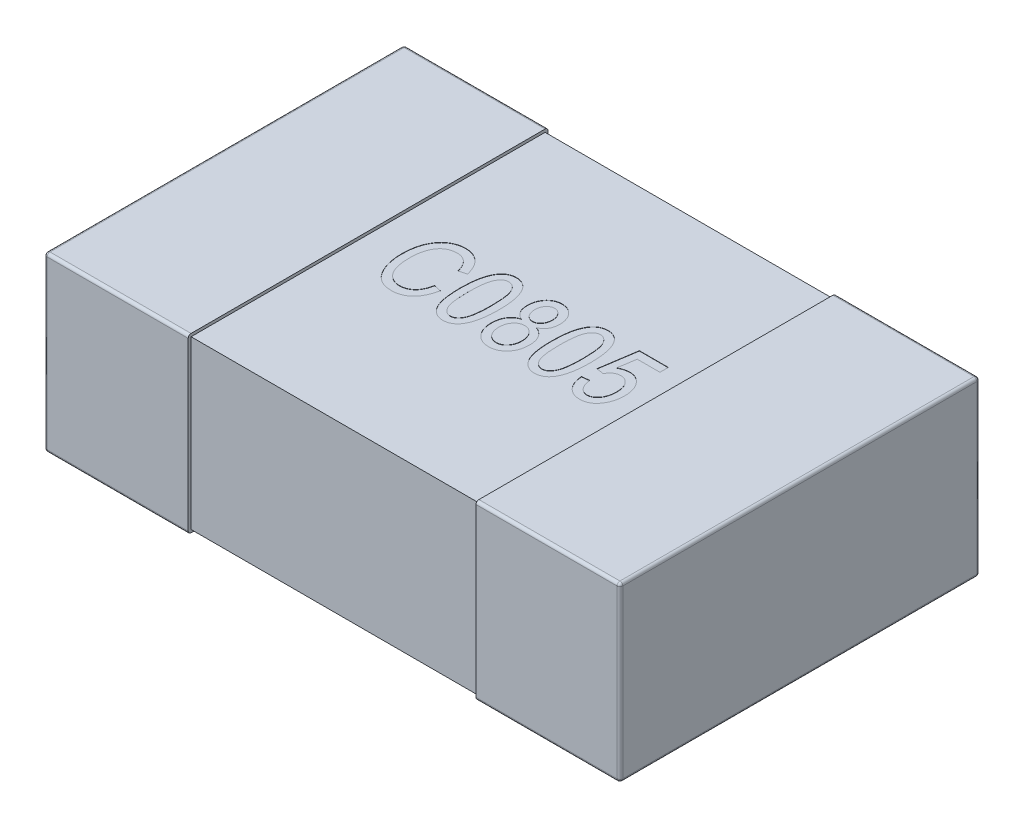
from build123d import *

# Parameters (mm, degrees)
SKETCH1_W            = 0.5
SKETCH1_H            = 1.25
THICKNESS_DEPTH      = 0.6
FILLET1_R            = 0.01
SKETCH2_W            = 1.23
SKETCH2_H            = 0.58
BOSS_EXTRUDE2_DEPTH  = 0.5
FILLET1_OF_MIRROR3_R = 0.01
CUT_EXTRUDE1_DEPTH   = 0.001


with BuildPart() as part:
    # Sketch1 → THICKNESS (new body)
    with BuildSketch(Plane(origin=(0, 0, 0), x_dir=(1, 0, 0), z_dir=(0, 1, 0))):
        with Locations((-0.75, 0)):
            Rectangle(SKETCH1_W, SKETCH1_H)
    thickness = extrude(amount=THICKNESS_DEPTH)

    # Fillet1
    fillet1_edges = [part.edges().sort_by_distance(p)[0] for p in [
        (-0.75, 0.6, -0.625),
        (-1, 0.6, 0),
        (-0.75, 0, -0.625),
        (-0.75, 0, 0.625),
        (-1, 0, 0),
        (-0.75, 0.6, 0.625),
        (-1, 0.3, -0.625),
        (-1, 0.3, 0.625),
    ]]
    fillet(fillet1_edges, radius=FILLET1_R)

    # Sketch2 → Boss-Extrude2 (add)
    with BuildSketch(Plane(origin=(0, 0, 0), x_dir=(0, 0, -1), z_dir=(1, 0, 0))):
        with Locations((0, 0.3)):
            Rectangle(SKETCH2_W, SKETCH2_H)
    boss_extrude2 = extrude(amount=-BOSS_EXTRUDE2_DEPTH)

    # Mirror3: THICKNESS, Boss-Extrude2 across plane
    add(thickness.mirror(Plane(origin=(0, 0, 0), x_dir=(0, 0, 1), z_dir=(1, 0, 0))))
    add(boss_extrude2.mirror(Plane(origin=(0, 0, 0), x_dir=(0, 0, 1), z_dir=(1, 0, 0))))

    # Fillet1 of Mirror3
    fillet1_of_mirror3_edges = [part.edges().sort_by_distance(p)[0] for p in [
        (0.75, 0.6, -0.625),
        (1, 0.6, 0),
        (0.75, 0, -0.625),
        (0.75, 0, 0.625),
        (1, 0, 0),
        (0.75, 0.6, 0.625),
        (1, 0.3, -0.625),
        (1, 0.3, 0.625),
    ]]
    fillet(fillet1_of_mirror3_edges, radius=FILLET1_OF_MIRROR3_R)

    # Sketch3 → Cut-Extrude1 (cut)
    with BuildSketch(Plane(origin=(0, 0.59, 0), x_dir=(1, 0, 0), z_dir=(0, 1, 0))):
        with BuildLine():
            Line((-0.231168831, -0.037337662), (-0.205194805, -0.043831169))
            add(Edge.make_bspline(
                [(-0.205194805, -0.043831169), (-0.205968965, -0.047273204), (-0.207478255, -0.053983737), (-0.210309184, -0.063635675), (-0.213617187, -0.072593423), (-0.217311677, -0.080890917), (-0.22142228, -0.088529429), (-0.22592876, -0.095503706), (-0.230869053, -0.101808046), (-0.236267766, -0.107364816), (-0.241944682, -0.112350711), (-0.248032026, -0.116535886), (-0.254346658, -0.120203809), (-0.26100923, -0.12312515), (-0.267952491, -0.12543899), (-0.275213822, -0.127035185), (-0.28276372, -0.128104831), (-0.287915608, -0.128199056), (-0.290523539, -0.128246753)],
                knots=[0, 0, 0, 0, 1.0582e-05, 2.0631e-05, 3.0149e-05, 3.921e-05, 4.7858e-05, 5.6146e-05, 6.4092e-05, 7.1842e-05, 7.9358e-05, 8.6719e-05, 9.3968e-05, 0.000101235, 0.000108503, 0.000115887, 0.000123514, 0.000131332, 0.000131332, 0.000131332, 0.000131332], degree=3))
            add(Edge.make_bspline(
                [(-0.290523539, -0.128246753), (-0.292825256, -0.128214993), (-0.297337162, -0.128152735), (-0.303977054, -0.127448949), (-0.310377642, -0.126420938), (-0.316524107, -0.124873245), (-0.322429991, -0.122978556), (-0.32803827, -0.120545225), (-0.333440076, -0.117775927), (-0.33857358, -0.114503183), (-0.343499773, -0.110795587), (-0.348086449, -0.106484738), (-0.352555473, -0.101772489), (-0.356677828, -0.096433674), (-0.360733341, -0.090681143), (-0.364379303, -0.084299811), (-0.367916321, -0.077476372), (-0.371173624, -0.07015596), (-0.374207584, -0.062412188), (-0.376685204, -0.054233559), (-0.37889496, -0.045762414), (-0.380648734, -0.036933097), (-0.382095747, -0.02778229), (-0.38301208, -0.018260327), (-0.383659727, -0.008413308), (-0.383730335, -0.001725961), (-0.383766234, 0.001674107)],
                knots=[0, 0, 0, 0, 6.902e-06, 1.353e-05, 2.001e-05, 2.6335e-05, 3.2527e-05, 3.8596e-05, 4.4654e-05, 5.072e-05, 5.6838e-05, 6.312e-05, 6.9581e-05, 7.63e-05, 8.3336e-05, 9.0679e-05, 9.8325e-05, 0.000106387, 0.000114706, 0.000123258, 0.000132006, 0.000140961, 0.000150252, 0.000159787, 0.000169648, 0.000179847, 0.000179847, 0.000179847, 0.000179847], degree=3))
            add(Edge.make_bspline(
                [(-0.383766234, 0.001674107), (-0.383730628, 0.005023478), (-0.383660793, 0.011592639), (-0.383014207, 0.021236978), (-0.382100205, 0.030506464), (-0.380648094, 0.039369282), (-0.378906317, 0.047863998), (-0.376704809, 0.055934078), (-0.374190115, 0.063645915), (-0.371199841, 0.070925759), (-0.367830189, 0.07777941), (-0.364229433, 0.084235387), (-0.360389227, 0.090294277), (-0.356221673, 0.09589401), (-0.351749021, 0.101020684), (-0.347007571, 0.105725638), (-0.341972704, 0.10997961), (-0.336702676, 0.113859575), (-0.331180168, 0.117222312), (-0.325519076, 0.12020861), (-0.319676812, 0.122686433), (-0.313674698, 0.124722564), (-0.307518536, 0.126305307), (-0.301206006, 0.12739352), (-0.294753004, 0.128161063), (-0.290390553, 0.128218021), (-0.288189935, 0.128246753)],
                knots=[0, 0, 0, 0, 1.0047e-05, 1.9705e-05, 2.8988e-05, 3.7979e-05, 4.6635e-05, 5.4991e-05, 6.306e-05, 7.0954e-05, 7.8578e-05, 8.5959e-05, 9.3122e-05, 0.000100082, 0.000106878, 0.000113515, 0.000120101, 0.000126636, 0.000133126, 0.00013948, 0.000145821, 0.000152142, 0.000158479, 0.000164868, 0.000171349, 0.000177948, 0.000177948, 0.000177948, 0.000177948], degree=3))
            add(Edge.make_bspline(
                [(-0.288189935, 0.128246753), (-0.285786544, 0.12818453), (-0.281065468, 0.128062302), (-0.27409222, 0.12720637), (-0.267421527, 0.125649629), (-0.260941178, 0.123644025), (-0.254772783, 0.120932796), (-0.248836643, 0.117670986), (-0.243184534, 0.113789845), (-0.237812765, 0.10931328), (-0.232727167, 0.104296702), (-0.228042938, 0.098687559), (-0.223802839, 0.092510719), (-0.219842083, 0.085852669), (-0.216430726, 0.078551126), (-0.213354929, 0.070734496), (-0.21055449, 0.062389431), (-0.209157696, 0.05656012), (-0.208441558, 0.053571429)],
                knots=[0, 0, 0, 0, 7.21e-06, 1.4163e-05, 2.103e-05, 2.7737e-05, 3.4485e-05, 4.1206e-05, 4.803e-05, 5.5019e-05, 6.2158e-05, 6.9433e-05, 7.6905e-05, 8.4614e-05, 9.2647e-05, 0.00010105, 0.000109809, 0.000119025, 0.000119025, 0.000119025, 0.000119025], degree=3))
            Line((-0.208441558, 0.053571429), (-0.234415584, 0.047077922))
            add(Edge.make_bspline(
                [(-0.234415584, 0.047077922), (-0.23500265, 0.049181367), (-0.236147605, 0.053283718), (-0.238185085, 0.059175943), (-0.240413527, 0.064665864), (-0.242835415, 0.069768302), (-0.245532383, 0.074438981), (-0.248425607, 0.078715963), (-0.251520038, 0.082611153), (-0.254880673, 0.08604242), (-0.258395665, 0.089138381), (-0.262172725, 0.091790554), (-0.266180492, 0.094006199), (-0.27038275, 0.095868718), (-0.274792779, 0.097269665), (-0.279425079, 0.098301565), (-0.284267339, 0.098910232), (-0.287579473, 0.098987088), (-0.289255276, 0.099025974)],
                knots=[0, 0, 0, 0, 6.55e-06, 1.2775e-05, 1.8691e-05, 2.4318e-05, 2.9705e-05, 3.4855e-05, 3.9798e-05, 4.4606e-05, 4.9244e-05, 5.3833e-05, 5.842e-05, 6.2963e-05, 6.76e-05, 7.2277e-05, 7.7185e-05, 8.2211e-05, 8.2211e-05, 8.2211e-05, 8.2211e-05], degree=3))
            add(Edge.make_bspline(
                [(-0.289255276, 0.099025974), (-0.292562979, 0.098903427), (-0.299017461, 0.098664295), (-0.308352597, 0.096675161), (-0.317038414, 0.093493465), (-0.323649229, 0.089675624), (-0.328550756, 0.086013742), (-0.332025044, 0.082883115), (-0.33529639, 0.079388167), (-0.338404619, 0.075562178), (-0.341348899, 0.071373856), (-0.344004018, 0.066772211), (-0.346579011, 0.061887791), (-0.348899355, 0.056616335), (-0.35096647, 0.050986827), (-0.352805045, 0.045011451), (-0.35437315, 0.038679632), (-0.355638058, 0.031972096), (-0.356578558, 0.02490781), (-0.357303678, 0.017480962), (-0.357693038, 0.009693713), (-0.357758745, 0.004380116), (-0.357792208, 0.001674107)],
                knots=[0, 0, 0, 0, 9.914e-06, 1.9346e-05, 2.8496e-05, 3.7564e-05, 4.2129e-05, 4.6835e-05, 5.1572e-05, 5.6477e-05, 6.1614e-05, 6.6912e-05, 7.2403e-05, 7.8172e-05, 8.4175e-05, 9.0385e-05, 9.6919e-05, 0.000103734, 0.000110851, 0.000118292, 0.000126115, 0.000134233, 0.000134233, 0.000134233, 0.000134233], degree=3))
            add(Edge.make_bspline(
                [(-0.357792208, 0.001674107), (-0.357728045, -0.002385607), (-0.357603596, -0.010259723), (-0.356810064, -0.021695507), (-0.355421735, -0.032360536), (-0.353383666, -0.042219257), (-0.350866218, -0.051303395), (-0.347803354, -0.059616425), (-0.344078971, -0.067123445), (-0.339824042, -0.073840071), (-0.335076544, -0.079761457), (-0.32995428, -0.084920573), (-0.324424924, -0.089264712), (-0.318555631, -0.09287674), (-0.312259011, -0.095608828), (-0.305623473, -0.097607303), (-0.298598123, -0.098792817), (-0.293791734, -0.098947114), (-0.291335227, -0.099025974)],
                knots=[0, 0, 0, 0, 1.2179e-05, 2.3622e-05, 3.437e-05, 4.4419e-05, 5.3798e-05, 6.2627e-05, 7.0954e-05, 7.8891e-05, 8.6434e-05, 9.368e-05, 0.000100652, 0.000107482, 0.000114296, 0.000121182, 0.000128229, 0.000135596, 0.000135596, 0.000135596, 0.000135596], degree=3))
            add(Edge.make_bspline(
                [(-0.291335227, -0.099025974), (-0.289506447, -0.098975677), (-0.285902636, -0.098876561), (-0.280589632, -0.098136185), (-0.27545054, -0.096991349), (-0.270498383, -0.095311137), (-0.265786495, -0.093096502), (-0.261219796, -0.090518091), (-0.256892634, -0.087376125), (-0.252744503, -0.083801559), (-0.248860727, -0.079713192), (-0.245310264, -0.075115309), (-0.242039551, -0.07004538), (-0.239233703, -0.064419613), (-0.23668226, -0.058355899), (-0.234454991, -0.051798345), (-0.232574721, -0.044746988), (-0.231644997, -0.039847153), (-0.231168831, -0.037337662)],
                knots=[0, 0, 0, 0, 5.485e-06, 1.0808e-05, 1.6063e-05, 2.1261e-05, 2.6459e-05, 3.1663e-05, 3.697e-05, 4.2473e-05, 4.8071e-05, 5.3855e-05, 5.9878e-05, 6.614e-05, 7.2688e-05, 7.9602e-05, 8.69e-05, 9.456e-05, 9.456e-05, 9.456e-05, 9.456e-05], degree=3))
        make_face()
        with BuildLine():
            add(Edge.make_bspline(
                [(-0.179220779, -0.000101461), (-0.179179533, 0.005006574), (-0.179099444, 0.014925148), (-0.178271735, 0.029310918), (-0.176966194, 0.042750423), (-0.175190833, 0.055225643), (-0.172788092, 0.066738449), (-0.169958625, 0.077307314), (-0.166483475, 0.086898626), (-0.162571978, 0.095553513), (-0.158086391, 0.103223649), (-0.153141222, 0.10993539), (-0.147589777, 0.115579805), (-0.141585133, 0.120273356), (-0.135007833, 0.12384902), (-0.127951495, 0.126418777), (-0.120390032, 0.127969473), (-0.115172358, 0.128153074), (-0.112510146, 0.128246753)],
                knots=[0, 0, 0, 0, 1.5323e-05, 2.9753e-05, 4.3211e-05, 5.5823e-05, 6.7534e-05, 7.8475e-05, 8.8617e-05, 9.8105e-05, 0.000106928, 0.000115227, 0.000123048, 0.000130607, 0.000138008, 0.000145407, 0.000153068, 0.000161049, 0.000161049, 0.000161049, 0.000161049], degree=3))
            add(Edge.make_bspline(
                [(-0.112510146, 0.128246753), (-0.11013769, 0.128170646), (-0.105478729, 0.12802119), (-0.098680126, 0.126788688), (-0.092285601, 0.124691913), (-0.086290323, 0.121778021), (-0.080712505, 0.118015925), (-0.075497266, 0.11346708), (-0.070701759, 0.108039774), (-0.067924896, 0.10396259), (-0.066497565, 0.101866883)],
                knots=[0, 0, 0, 0, 7.114e-06, 1.397e-05, 2.0644e-05, 2.7246e-05, 3.3901e-05, 4.0769e-05, 4.7956e-05, 5.5558e-05, 5.5558e-05, 5.5558e-05, 5.5558e-05], degree=3))
            add(Edge.make_bspline(
                [(-0.066497565, 0.101866883), (-0.064845388, 0.099041395), (-0.061409512, 0.093165494), (-0.05730691, 0.083320552), (-0.053848794, 0.072324578), (-0.050933052, 0.060142576), (-0.048853186, 0.046749428), (-0.0472071, 0.032197231), (-0.046254426, 0.016449408), (-0.046155276, 0.00554781), (-0.046103896, -0.000101461)],
                knots=[0, 0, 0, 0, 9.81e-06, 2.0402e-05, 3.1905e-05, 4.437e-05, 5.7939e-05, 7.2539e-05, 8.8295e-05, 0.000105241, 0.000105241, 0.000105241, 0.000105241], degree=3))
            add(Edge.make_bspline(
                [(-0.046103896, -0.000101461), (-0.046144642, -0.00517574), (-0.046223745, -0.01502685), (-0.047059737, -0.029344109), (-0.048347884, -0.042718306), (-0.050147358, -0.055155476), (-0.052527816, -0.066640018), (-0.055394879, -0.077206009), (-0.058761574, -0.086848769), (-0.062727214, -0.095504579), (-0.067146769, -0.103219465), (-0.072175828, -0.109863192), (-0.077593483, -0.115608492), (-0.083676071, -0.120200381), (-0.090208492, -0.123877255), (-0.097312386, -0.1264037), (-0.104899054, -0.127976131), (-0.110134815, -0.128155136), (-0.112814529, -0.128246753)],
                knots=[0, 0, 0, 0, 1.5221e-05, 2.955e-05, 4.3008e-05, 5.552e-05, 6.7231e-05, 7.8172e-05, 8.8344e-05, 9.7833e-05, 0.000106699, 0.000114958, 0.000122779, 0.000130308, 0.000137734, 0.00014518, 0.000152841, 0.000160872, 0.000160872, 0.000160872, 0.000160872], degree=3))
            add(Edge.make_bspline(
                [(-0.112814529, -0.128246753), (-0.115204627, -0.128157044), (-0.119903828, -0.127980665), (-0.126798792, -0.126639628), (-0.1333245, -0.124327432), (-0.139515421, -0.121150834), (-0.145379788, -0.117089582), (-0.150845947, -0.112058129), (-0.156045963, -0.10618892), (-0.160917296, -0.099373751), (-0.165319285, -0.091437437), (-0.16904038, -0.082191081), (-0.172210639, -0.071678848), (-0.174726393, -0.059858298), (-0.176843902, -0.046777746), (-0.178174674, -0.032371584), (-0.179056727, -0.016667611), (-0.179164667, -0.005767747), (-0.179220779, -0.000101461)],
                knots=[0, 0, 0, 0, 7.168e-06, 1.4092e-05, 2.0975e-05, 2.7873e-05, 3.4909e-05, 4.2307e-05, 5.0105e-05, 5.8397e-05, 6.7389e-05, 7.7262e-05, 8.8239e-05, 0.00010029, 0.000113492, 0.00012797, 0.000143669, 0.000160667, 0.000160667, 0.000160667, 0.000160667], degree=3))
        make_face()
        with BuildLine():
            add(Edge.make_bspline(
                [(-0.153246753, 0), (-0.153201463, -0.004870478), (-0.153114944, -0.014174538), (-0.152639473, -0.027525997), (-0.151740786, -0.039609099), (-0.150492603, -0.050461919), (-0.148910111, -0.060039625), (-0.146956953, -0.068394949), (-0.144629573, -0.075493918), (-0.141891409, -0.081437608), (-0.138854976, -0.086371634), (-0.135611674, -0.090576008), (-0.1322582, -0.09422232), (-0.128592398, -0.097134983), (-0.124786606, -0.099490077), (-0.120693762, -0.101026781), (-0.116458236, -0.102135963), (-0.113532141, -0.102226818), (-0.112053571, -0.102272727)],
                knots=[0, 0, 0, 0, 1.4612e-05, 2.7913e-05, 4.0072e-05, 5.0952e-05, 6.0676e-05, 6.9179e-05, 7.667e-05, 8.3048e-05, 8.8764e-05, 9.401e-05, 9.8963e-05, 0.000103582, 0.000108019, 0.000112324, 0.000116655, 0.000121079, 0.000121079, 0.000121079, 0.000121079], degree=3))
            add(Edge.make_bspline(
                [(-0.112053571, -0.102272727), (-0.110659797, -0.102224591), (-0.107884569, -0.102128745), (-0.103839162, -0.101030887), (-0.099939203, -0.099420452), (-0.096250237, -0.097089742), (-0.09277756, -0.094091995), (-0.089474108, -0.090452458), (-0.086334961, -0.086167132), (-0.083324707, -0.081159117), (-0.080615636, -0.075185232), (-0.078311364, -0.068052529), (-0.076372444, -0.059699885), (-0.074768611, -0.050127164), (-0.073606683, -0.039317254), (-0.072676443, -0.027307128), (-0.072213316, -0.014055917), (-0.072124348, -0.00481966), (-0.072077922, 0)],
                knots=[0, 0, 0, 0, 4.171e-06, 8.305e-06, 1.2489e-05, 1.6796e-05, 2.133e-05, 2.6213e-05, 3.151e-05, 3.7243e-05, 4.3713e-05, 5.1141e-05, 5.9692e-05, 6.9417e-05, 8.0241e-05, 9.2298e-05, 0.000105549, 0.000120008, 0.000120008, 0.000120008, 0.000120008], degree=3))
            add(Edge.make_bspline(
                [(-0.072077922, 0), (-0.072124141, 0.00487042), (-0.072212754, 0.014208164), (-0.072677993, 0.027577286), (-0.073592986, 0.039692504), (-0.074819086, 0.050531851), (-0.076431911, 0.060120015), (-0.078346386, 0.068469507), (-0.080711821, 0.075554192), (-0.083411098, 0.081486026), (-0.086509334, 0.086376159), (-0.089672696, 0.090644348), (-0.093139282, 0.094200445), (-0.096783038, 0.09716158), (-0.100657033, 0.099469005), (-0.104778265, 0.101117847), (-0.109114692, 0.102110041), (-0.112082311, 0.102218271), (-0.113575487, 0.102272727)],
                knots=[0, 0, 0, 0, 1.4612e-05, 2.8014e-05, 4.0123e-05, 5.1053e-05, 6.0727e-05, 6.9279e-05, 7.6723e-05, 8.3101e-05, 8.8774e-05, 9.406e-05, 9.9011e-05, 0.00010363, 0.00010811, 0.000112482, 0.0001169, 0.000121375, 0.000121375, 0.000121375, 0.000121375], degree=3))
            add(Edge.make_bspline(
                [(-0.113575487, 0.102272727), (-0.114969489, 0.102225863), (-0.117728739, 0.102133101), (-0.121740511, 0.101030616), (-0.125589213, 0.099418598), (-0.129251156, 0.09707752), (-0.132680131, 0.094037526), (-0.136010373, 0.090420532), (-0.139080674, 0.086096557), (-0.142101966, 0.081134389), (-0.14476353, 0.075144526), (-0.147071377, 0.068024231), (-0.148927552, 0.059656603), (-0.150567782, 0.050112686), (-0.151714861, 0.039316591), (-0.152649199, 0.027307333), (-0.153111081, 0.014055859), (-0.153200232, 0.00481964), (-0.153246753, 0)],
                knots=[0, 0, 0, 0, 4.171e-06, 8.256e-06, 1.2393e-05, 1.6657e-05, 2.1224e-05, 2.6108e-05, 3.1374e-05, 3.7107e-05, 4.351e-05, 5.0986e-05, 5.9526e-05, 6.9201e-05, 8.0024e-05, 9.2082e-05, 0.000105332, 0.000119792, 0.000119792, 0.000119792, 0.000119792], degree=3))
        make_face(mode=Mode.SUBTRACT)
        with BuildLine():
            add(Edge.make_bspline(
                [(0.019997971, 0.012175325), (0.017608115, 0.0133763), (0.012945467, 0.015719422), (0.006730686, 0.02030892), (0.001431301, 0.02563882), (-0.002934005, 0.031747513), (-0.006311444, 0.038640955), (-0.008659668, 0.046294944), (-0.010186541, 0.054694639), (-0.010320164, 0.060565062), (-0.01038961, 0.063616071)],
                knots=[0, 0, 0, 0, 8.013e-06, 1.5633e-05, 2.3058e-05, 3.0477e-05, 3.8055e-05, 4.5981e-05, 5.443e-05, 6.3572e-05, 6.3572e-05, 6.3572e-05, 6.3572e-05], degree=3))
            add(Edge.make_bspline(
                [(-0.01038961, 0.063616071), (-0.010343103, 0.065951742), (-0.010252187, 0.070517631), (-0.009476242, 0.077204767), (-0.008201828, 0.083544039), (-0.006514602, 0.089582043), (-0.004180434, 0.095226916), (-0.001458777, 0.10061212), (0.001863052, 0.105617845), (0.005597262, 0.110289613), (0.009741509, 0.114475142), (0.014170998, 0.118154266), (0.018871487, 0.121287748), (0.023853046, 0.123813893), (0.029069863, 0.12581356), (0.034542692, 0.127254407), (0.04028381, 0.128047994), (0.044194159, 0.128179925), (0.046174919, 0.128246753)],
                knots=[0, 0, 0, 0, 7.005e-06, 1.3695e-05, 2.0161e-05, 2.6391e-05, 3.2467e-05, 3.8457e-05, 4.4465e-05, 5.0455e-05, 5.6374e-05, 6.2103e-05, 6.7703e-05, 7.3284e-05, 7.8824e-05, 8.4435e-05, 9.0225e-05, 9.6168e-05, 9.6168e-05, 9.6168e-05, 9.6168e-05], degree=3))
            add(Edge.make_bspline(
                [(0.046174919, 0.128246753), (0.048173364, 0.128185644), (0.052121341, 0.128064921), (0.057903749, 0.127188225), (0.063429828, 0.125762902), (0.068699633, 0.123781922), (0.073704751, 0.121173058), (0.078412963, 0.1179611), (0.08288259, 0.114205513), (0.087054016, 0.109930777), (0.090840174, 0.105185973), (0.094140446, 0.100073908), (0.09702712, 0.094687108), (0.099296313, 0.088906486), (0.101078339, 0.082793196), (0.102327483, 0.076339823), (0.103108743, 0.069570771), (0.103200164, 0.064954147), (0.103246753, 0.062601461)],
                knots=[0, 0, 0, 0, 5.994e-06, 1.1841e-05, 1.7501e-05, 2.3088e-05, 2.8693e-05, 3.4392e-05, 4.0153e-05, 4.618e-05, 5.228e-05, 5.8331e-05, 6.4413e-05, 7.0583e-05, 7.6924e-05, 8.3491e-05, 9.0281e-05, 9.7337e-05, 9.7337e-05, 9.7337e-05, 9.7337e-05], degree=3))
            add(Edge.make_bspline(
                [(0.103246753, 0.062601461), (0.103172617, 0.059669122), (0.103029811, 0.054020637), (0.101556925, 0.045908671), (0.099263984, 0.038471636), (0.095925511, 0.031751468), (0.09165802, 0.025713207), (0.08641722, 0.020415964), (0.080255733, 0.015741534), (0.075574525, 0.013387649), (0.073163555, 0.012175325)],
                knots=[0, 0, 0, 0, 8.788e-06, 1.6929e-05, 2.4646e-05, 3.2065e-05, 3.9342e-05, 4.6732e-05, 5.4341e-05, 6.2423e-05, 6.2423e-05, 6.2423e-05, 6.2423e-05], degree=3))
            add(Edge.make_bspline(
                [(0.073163555, 0.012175325), (0.074730856, 0.011541303), (0.077834464, 0.010285797), (0.082229601, 0.007982466), (0.086375933, 0.00545861), (0.090181987, 0.002585376), (0.093761575, -0.000514351), (0.097067658, -0.003914682), (0.100060041, -0.007626133), (0.102743529, -0.011613566), (0.105220068, -0.015818365), (0.107256823, -0.020346538), (0.109067857, -0.025076774), (0.110466335, -0.030075821), (0.111587213, -0.035311267), (0.112380412, -0.040785545), (0.11292046, -0.046509091), (0.112964473, -0.050407914), (0.112987013, -0.052404627)],
                knots=[0, 0, 0, 0, 5.069e-06, 1.0038e-05, 1.4867e-05, 1.9616e-05, 2.4326e-05, 2.9062e-05, 3.3823e-05, 3.8607e-05, 4.3471e-05, 4.8442e-05, 5.3483e-05, 5.8654e-05, 6.3997e-05, 6.9536e-05, 7.524e-05, 8.1228e-05, 8.1228e-05, 8.1228e-05, 8.1228e-05], degree=3))
            add(Edge.make_bspline(
                [(0.112987013, -0.052404627), (0.112924289, -0.055128971), (0.112801245, -0.06047322), (0.111962079, -0.068307174), (0.110406011, -0.075745841), (0.108359177, -0.082827048), (0.105643865, -0.089491503), (0.102393485, -0.095804559), (0.098464689, -0.101681027), (0.094011502, -0.107147985), (0.089143503, -0.11208587), (0.083913765, -0.116389256), (0.07842076, -0.120067116), (0.072613938, -0.123097907), (0.066477918, -0.125351504), (0.060103133, -0.127070716), (0.05342392, -0.128019792), (0.048883285, -0.128170387), (0.046580763, -0.128246753)],
                knots=[0, 0, 0, 0, 8.173e-06, 1.6033e-05, 2.3595e-05, 3.0947e-05, 3.8116e-05, 4.515e-05, 5.2213e-05, 5.928e-05, 6.6275e-05, 7.2979e-05, 7.9563e-05, 8.6075e-05, 9.2577e-05, 9.9136e-05, 0.000105851, 0.000112759, 0.000112759, 0.000112759, 0.000112759], degree=3))
            add(Edge.make_bspline(
                [(0.046580763, -0.128246753), (0.044244329, -0.128171234), (0.039652912, -0.128022829), (0.03290762, -0.127068643), (0.02649382, -0.125363058), (0.020335464, -0.123083058), (0.014493798, -0.120085393), (0.008992181, -0.116370481), (0.003713386, -0.112106017), (-0.001145795, -0.107141214), (-0.005635397, -0.101693384), (-0.009463549, -0.095719505), (-0.012816475, -0.089395075), (-0.015489055, -0.08261756), (-0.01757827, -0.075433101), (-0.019021856, -0.067821782), (-0.019966305, -0.059818075), (-0.02007467, -0.054335152), (-0.02012987, -0.051542208)],
                knots=[0, 0, 0, 0, 7.01e-06, 1.3775e-05, 2.0383e-05, 2.6885e-05, 3.3442e-05, 4.0026e-05, 4.6769e-05, 5.3764e-05, 6.0831e-05, 6.7909e-05, 7.5012e-05, 8.2275e-05, 8.9724e-05, 9.7425e-05, 0.000105492, 0.000113868, 0.000113868, 0.000113868, 0.000113868], degree=3))
            add(Edge.make_bspline(
                [(-0.02012987, -0.051542208), (-0.020105339, -0.049495029), (-0.020057209, -0.04547859), (-0.019540722, -0.039580678), (-0.018679815, -0.033957395), (-0.017517657, -0.028617709), (-0.016051589, -0.02355646), (-0.014221417, -0.018770161), (-0.012043174, -0.014258951), (-0.009538475, -0.01002366), (-0.006767647, -0.006078371), (-0.003716303, -0.002457397), (-0.000392604, 0.00080643), (0.003173052, 0.003755844), (0.006986329, 0.006425967), (0.011099416, 0.008682661), (0.015442133, 0.010640312), (0.018466467, 0.01165931), (0.019997971, 0.012175325)],
                knots=[0, 0, 0, 0, 6.14e-06, 1.2047e-05, 1.7744e-05, 2.3197e-05, 2.843e-05, 3.3536e-05, 3.8551e-05, 4.344e-05, 4.8282e-05, 5.2998e-05, 5.7626e-05, 6.2237e-05, 6.6867e-05, 7.1568e-05, 7.6291e-05, 8.1137e-05, 8.1137e-05, 8.1137e-05, 8.1137e-05], degree=3))
        make_face()
        with BuildLine():
            add(Edge.make_bspline(
                [(0.015584416, 0.064326299), (0.015681946, 0.061426273), (0.015868564, 0.055877292), (0.017543422, 0.047987942), (0.020396088, 0.041038149), (0.024300914, 0.035093735), (0.029077906, 0.030376067), (0.034405847, 0.026834075), (0.040339547, 0.024704984), (0.044484134, 0.024469682), (0.046580763, 0.024350649)],
                knots=[0, 0, 0, 0, 8.693e-06, 1.6633e-05, 2.4048e-05, 3.1111e-05, 3.7819e-05, 4.4052e-05, 5.0181e-05, 5.6456e-05, 5.6456e-05, 5.6456e-05, 5.6456e-05], degree=3))
            add(Edge.make_bspline(
                [(0.046580763, 0.024350649), (0.048645523, 0.024467069), (0.052728084, 0.024697261), (0.058534425, 0.026865702), (0.063852353, 0.030256885), (0.068520979, 0.034949179), (0.072428184, 0.040686016), (0.075291127, 0.047324407), (0.076983146, 0.054755983), (0.07717379, 0.059954406), (0.077272727, 0.062652192)],
                knots=[0, 0, 0, 0, 6.174e-06, 1.2207e-05, 1.8343e-05, 2.4979e-05, 3.1916e-05, 3.905e-05, 4.6545e-05, 5.463e-05, 5.463e-05, 5.463e-05, 5.463e-05], degree=3))
            add(Edge.make_bspline(
                [(0.077272727, 0.062652192), (0.077177636, 0.065435004), (0.07699413, 0.070805279), (0.075251187, 0.078454847), (0.072329537, 0.085316018), (0.068261855, 0.091197581), (0.063522513, 0.096087467), (0.058182877, 0.099640676), (0.052379995, 0.101873404), (0.048324957, 0.102138701), (0.04627638, 0.102272727)],
                knots=[0, 0, 0, 0, 8.338e-06, 1.6092e-05, 2.3386e-05, 3.0576e-05, 3.7428e-05, 4.3689e-05, 4.9692e-05, 5.5821e-05, 5.5821e-05, 5.5821e-05, 5.5821e-05], degree=3))
            add(Edge.make_bspline(
                [(0.04627638, 0.102272727), (0.044229121, 0.102155063), (0.04018065, 0.101922381), (0.034382091, 0.09975932), (0.029097082, 0.096239407), (0.024422055, 0.091481379), (0.020428846, 0.085787592), (0.017664797, 0.079208436), (0.015852196, 0.071999073), (0.01567571, 0.066942191), (0.015584416, 0.064326299)],
                knots=[0, 0, 0, 0, 6.123e-06, 1.2109e-05, 1.83e-05, 2.5044e-05, 3.2009e-05, 3.903e-05, 4.6339e-05, 5.4171e-05, 5.4171e-05, 5.4171e-05, 5.4171e-05], degree=3))
        make_face(mode=Mode.SUBTRACT)
        with BuildLine():
            add(Edge.make_bspline(
                [(0.005844156, -0.051440747), (0.005884873, -0.053302408), (0.005964642, -0.056949654), (0.006536311, -0.062272698), (0.007418802, -0.067322331), (0.008764466, -0.072065995), (0.010425021, -0.07656287), (0.012508632, -0.080774419), (0.01497034, -0.084704052), (0.017720554, -0.088355861), (0.020828136, -0.091554825), (0.024032628, -0.09444962), (0.027409817, -0.096881589), (0.030975754, -0.098843506), (0.034676238, -0.100351385), (0.038510119, -0.101491776), (0.042498061, -0.102170047), (0.045208453, -0.102238214), (0.046580763, -0.102272727)],
                knots=[0, 0, 0, 0, 5.584e-06, 1.094e-05, 1.6045e-05, 2.0943e-05, 2.5711e-05, 3.0408e-05, 3.5011e-05, 3.9607e-05, 4.4092e-05, 4.8368e-05, 5.255e-05, 5.6546e-05, 6.055e-05, 6.4515e-05, 6.8526e-05, 7.264e-05, 7.264e-05, 7.264e-05, 7.264e-05], degree=3))
            add(Edge.make_bspline(
                [(0.046580763, -0.102272727), (0.047970557, -0.102240886), (0.050698993, -0.102178375), (0.05470781, -0.101468861), (0.058558747, -0.100428268), (0.062245393, -0.098930978), (0.065779462, -0.097047362), (0.069125944, -0.094704168), (0.072298569, -0.091910878), (0.075326353, -0.088766293), (0.07802805, -0.085196408), (0.080525134, -0.081414617), (0.082450424, -0.077244206), (0.084181872, -0.072878993), (0.085396866, -0.068167492), (0.08641322, -0.063198116), (0.086867911, -0.057908681), (0.08696394, -0.054299014), (0.087012987, -0.052455357)],
                knots=[0, 0, 0, 0, 4.165e-06, 8.176e-06, 1.2176e-05, 1.6114e-05, 2.0086e-05, 2.4167e-05, 2.8338e-05, 3.2752e-05, 3.7237e-05, 4.1754e-05, 4.6315e-05, 5.0988e-05, 5.5824e-05, 6.0888e-05, 6.6189e-05, 7.1722e-05, 7.1722e-05, 7.1722e-05, 7.1722e-05], degree=3))
            add(Edge.make_bspline(
                [(0.087012987, -0.052455357), (0.086970568, -0.050594015), (0.086887463, -0.046947395), (0.086339333, -0.041616781), (0.085371197, -0.036580034), (0.084046831, -0.03182905), (0.0823784, -0.027334315), (0.080300836, -0.023110366), (0.077802857, -0.019191134), (0.074946932, -0.01560315), (0.071895341, -0.012323666), (0.068638379, -0.009457317), (0.065207638, -0.007062986), (0.061653584, -0.00505338), (0.057925977, -0.003547349), (0.054078022, -0.0023968), (0.050054026, -0.001727338), (0.04731033, -0.001658319), (0.045921266, -0.001623377)],
                knots=[0, 0, 0, 0, 5.584e-06, 1.094e-05, 1.6054e-05, 2.0953e-05, 2.5721e-05, 3.0417e-05, 3.5047e-05, 3.9634e-05, 4.4157e-05, 4.8471e-05, 5.2623e-05, 5.6688e-05, 6.0692e-05, 6.4657e-05, 6.8718e-05, 7.2883e-05, 7.2883e-05, 7.2883e-05, 7.2883e-05], degree=3))
            add(Edge.make_bspline(
                [(0.045921266, -0.001623377), (0.044549268, -0.001658738), (0.041839492, -0.001728579), (0.0378631, -0.0023919), (0.034081875, -0.003563755), (0.030386814, -0.004975803), (0.026934724, -0.007036482), (0.023558253, -0.009387964), (0.020422725, -0.012279373), (0.017432548, -0.015503662), (0.014714112, -0.019088214), (0.012309924, -0.022948093), (0.010330764, -0.027091854), (0.008720132, -0.031482149), (0.00737612, -0.036100026), (0.00647224, -0.040993795), (0.005981738, -0.046137767), (0.005890687, -0.049647266), (0.005844156, -0.051440747)],
                knots=[0, 0, 0, 0, 4.114e-06, 8.126e-06, 1.2042e-05, 1.598e-05, 1.9957e-05, 2.4067e-05, 2.8305e-05, 3.2721e-05, 3.7247e-05, 4.178e-05, 4.6341e-05, 5.0996e-05, 5.5797e-05, 6.0752e-05, 6.5901e-05, 7.1282e-05, 7.1282e-05, 7.1282e-05, 7.1282e-05], degree=3))
        make_face(mode=Mode.SUBTRACT)
        with BuildLine():
            add(Edge.make_bspline(
                [(0.138961039, -0.000101461), (0.139002285, 0.005006574), (0.139082374, 0.014925148), (0.139910083, 0.029310918), (0.141215625, 0.042750423), (0.142990985, 0.055225643), (0.145393726, 0.066738449), (0.148223193, 0.077307314), (0.151698344, 0.086898626), (0.15560984, 0.095553513), (0.160095427, 0.103223649), (0.165040597, 0.10993539), (0.170592041, 0.115579805), (0.176596686, 0.120273356), (0.183173985, 0.12384902), (0.190230324, 0.126418777), (0.197791786, 0.127969473), (0.20300946, 0.128153074), (0.205671672, 0.128246753)],
                knots=[0, 0, 0, 0, 1.5323e-05, 2.9753e-05, 4.3211e-05, 5.5823e-05, 6.7534e-05, 7.8475e-05, 8.8617e-05, 9.8105e-05, 0.000106928, 0.000115227, 0.000123048, 0.000130607, 0.000138008, 0.000145407, 0.000153068, 0.000161049, 0.000161049, 0.000161049, 0.000161049], degree=3))
            add(Edge.make_bspline(
                [(0.205671672, 0.128246753), (0.208044128, 0.128170646), (0.212703089, 0.12802119), (0.219501692, 0.126788688), (0.225896217, 0.124691913), (0.231891495, 0.121778021), (0.237469313, 0.118015925), (0.242684552, 0.11346708), (0.247480059, 0.108039774), (0.250256922, 0.10396259), (0.251684253, 0.101866883)],
                knots=[0, 0, 0, 0, 7.114e-06, 1.397e-05, 2.0644e-05, 2.7246e-05, 3.3901e-05, 4.0769e-05, 4.7956e-05, 5.5558e-05, 5.5558e-05, 5.5558e-05, 5.5558e-05], degree=3))
            add(Edge.make_bspline(
                [(0.251684253, 0.101866883), (0.25333643, 0.099041395), (0.256772306, 0.093165494), (0.260874909, 0.083320552), (0.264333024, 0.072324578), (0.267248767, 0.060142576), (0.269328632, 0.046749428), (0.270974719, 0.032197231), (0.271927393, 0.016449408), (0.272026542, 0.00554781), (0.272077922, -0.000101461)],
                knots=[0, 0, 0, 0, 9.81e-06, 2.0402e-05, 3.1905e-05, 4.437e-05, 5.7939e-05, 7.2539e-05, 8.8295e-05, 0.000105241, 0.000105241, 0.000105241, 0.000105241], degree=3))
            add(Edge.make_bspline(
                [(0.272077922, -0.000101461), (0.272037176, -0.00517574), (0.271958073, -0.01502685), (0.271122081, -0.029344109), (0.269833934, -0.042718306), (0.26803446, -0.055155476), (0.265654003, -0.066640018), (0.262786939, -0.077206009), (0.259420244, -0.086848769), (0.255454604, -0.095504579), (0.251035049, -0.103219465), (0.24600599, -0.109863192), (0.240588335, -0.115608492), (0.234505748, -0.120200381), (0.227973326, -0.123877255), (0.220869432, -0.1264037), (0.213282764, -0.127976131), (0.208047003, -0.128155136), (0.205367289, -0.128246753)],
                knots=[0, 0, 0, 0, 1.5221e-05, 2.955e-05, 4.3008e-05, 5.552e-05, 6.7231e-05, 7.8172e-05, 8.8344e-05, 9.7833e-05, 0.000106699, 0.000114958, 0.000122779, 0.000130308, 0.000137734, 0.00014518, 0.000152841, 0.000160872, 0.000160872, 0.000160872, 0.000160872], degree=3))
            add(Edge.make_bspline(
                [(0.205367289, -0.128246753), (0.202977191, -0.128157044), (0.19827799, -0.127980665), (0.191383026, -0.126639628), (0.184857319, -0.124327432), (0.178666397, -0.121150834), (0.17280203, -0.117089582), (0.167335871, -0.112058129), (0.162135855, -0.10618892), (0.157264523, -0.099373751), (0.152862533, -0.091437437), (0.149141438, -0.082191081), (0.145971179, -0.071678848), (0.143455425, -0.059858298), (0.141337917, -0.046777746), (0.140007144, -0.032371584), (0.139125092, -0.016667611), (0.139017152, -0.005767747), (0.138961039, -0.000101461)],
                knots=[0, 0, 0, 0, 7.168e-06, 1.4092e-05, 2.0975e-05, 2.7873e-05, 3.4909e-05, 4.2307e-05, 5.0105e-05, 5.8397e-05, 6.7389e-05, 7.7262e-05, 8.8239e-05, 0.00010029, 0.000113492, 0.00012797, 0.000143669, 0.000160667, 0.000160667, 0.000160667, 0.000160667], degree=3))
        make_face()
        with BuildLine():
            add(Edge.make_bspline(
                [(0.164935065, 0), (0.164980356, -0.004870478), (0.165066874, -0.014174538), (0.165542345, -0.027525997), (0.166441032, -0.039609099), (0.167689215, -0.050461919), (0.169271707, -0.060039625), (0.171224865, -0.068394949), (0.173552246, -0.075493918), (0.176290409, -0.081437608), (0.179326842, -0.086371634), (0.182570144, -0.090576008), (0.185923618, -0.09422232), (0.18958942, -0.097134983), (0.193395212, -0.099490077), (0.197488056, -0.101026781), (0.201723582, -0.102135963), (0.204649677, -0.102226818), (0.206128247, -0.102272727)],
                knots=[0, 0, 0, 0, 1.4612e-05, 2.7913e-05, 4.0072e-05, 5.0952e-05, 6.0676e-05, 6.9179e-05, 7.667e-05, 8.3048e-05, 8.8764e-05, 9.401e-05, 9.8963e-05, 0.000103582, 0.000108019, 0.000112324, 0.000116655, 0.000121079, 0.000121079, 0.000121079, 0.000121079], degree=3))
            add(Edge.make_bspline(
                [(0.206128247, -0.102272727), (0.207522022, -0.102224591), (0.210297249, -0.102128745), (0.214342656, -0.101030887), (0.218242615, -0.099420452), (0.221931581, -0.097089742), (0.225404258, -0.094091995), (0.22870771, -0.090452458), (0.231846857, -0.086167132), (0.234857111, -0.081159117), (0.237566182, -0.075185232), (0.239870454, -0.068052529), (0.241809374, -0.059699885), (0.243413207, -0.050127164), (0.244575135, -0.039317254), (0.245505376, -0.027307128), (0.245968502, -0.014055917), (0.24605747, -0.00481966), (0.246103896, 0)],
                knots=[0, 0, 0, 0, 4.171e-06, 8.305e-06, 1.2489e-05, 1.6796e-05, 2.133e-05, 2.6213e-05, 3.151e-05, 3.7243e-05, 4.3713e-05, 5.1141e-05, 5.9692e-05, 6.9417e-05, 8.0241e-05, 9.2298e-05, 0.000105549, 0.000120008, 0.000120008, 0.000120008, 0.000120008], degree=3))
            add(Edge.make_bspline(
                [(0.246103896, 0), (0.246057677, 0.00487042), (0.245969064, 0.014208164), (0.245503825, 0.027577286), (0.244588833, 0.039692504), (0.243362732, 0.050531851), (0.241749907, 0.060120015), (0.239835432, 0.068469507), (0.237469998, 0.075554192), (0.23477072, 0.081486026), (0.231672484, 0.086376159), (0.228509123, 0.090644348), (0.225042536, 0.094200445), (0.22139878, 0.09716158), (0.217524785, 0.099469005), (0.213403553, 0.101117847), (0.209067126, 0.102110041), (0.206099507, 0.102218271), (0.204606331, 0.102272727)],
                knots=[0, 0, 0, 0, 1.4612e-05, 2.8014e-05, 4.0123e-05, 5.1053e-05, 6.0727e-05, 6.9279e-05, 7.6723e-05, 8.3101e-05, 8.8774e-05, 9.406e-05, 9.9011e-05, 0.00010363, 0.00010811, 0.000112482, 0.0001169, 0.000121375, 0.000121375, 0.000121375, 0.000121375], degree=3))
            add(Edge.make_bspline(
                [(0.204606331, 0.102272727), (0.203212329, 0.102225863), (0.20045308, 0.102133101), (0.196441307, 0.101030616), (0.192592605, 0.099418598), (0.188930663, 0.09707752), (0.185501687, 0.094037526), (0.182171446, 0.090420532), (0.179101144, 0.086096557), (0.176079852, 0.081134389), (0.173418288, 0.075144526), (0.171110441, 0.068024231), (0.169254266, 0.059656603), (0.167614036, 0.050112686), (0.166466957, 0.039316591), (0.165532619, 0.027307333), (0.165070737, 0.014055859), (0.164981586, 0.00481964), (0.164935065, 0)],
                knots=[0, 0, 0, 0, 4.171e-06, 8.256e-06, 1.2393e-05, 1.6657e-05, 2.1224e-05, 2.6108e-05, 3.1374e-05, 3.7107e-05, 4.351e-05, 5.0986e-05, 5.9526e-05, 6.9201e-05, 8.0024e-05, 9.2082e-05, 0.000105332, 0.000119792, 0.000119792, 0.000119792, 0.000119792], degree=3))
        make_face(mode=Mode.SUBTRACT)
        with BuildLine():
            Line((0.298051948, -0.056818182), (0.324025974, -0.053571429))
            add(Edge.make_bspline(
                [(0.324025974, -0.053571429), (0.32428961, -0.055553946), (0.32480339, -0.05941753), (0.325947565, -0.06497934), (0.327209581, -0.070190853), (0.32889461, -0.074949688), (0.330604039, -0.079408786), (0.332717252, -0.083403999), (0.334979139, -0.087053471), (0.337549345, -0.090238298), (0.34021846, -0.093103951), (0.343061674, -0.095528543), (0.346004561, -0.09759329), (0.349028569, -0.099329695), (0.352196781, -0.100664073), (0.355473386, -0.101567247), (0.358840423, -0.102148724), (0.361124525, -0.102231147), (0.362276786, -0.102272727)],
                knots=[0, 0, 0, 0, 5.998e-06, 1.1689e-05, 1.7029e-05, 2.2066e-05, 2.6823e-05, 3.1339e-05, 3.5603e-05, 3.9683e-05, 4.3595e-05, 4.7337e-05, 5.0869e-05, 5.4368e-05, 5.7778e-05, 6.1151e-05, 6.4545e-05, 6.8001e-05, 6.8001e-05, 6.8001e-05, 6.8001e-05], degree=3))
            add(Edge.make_bspline(
                [(0.362276786, -0.102272727), (0.36371776, -0.102225616), (0.366569478, -0.102132382), (0.370760229, -0.101337084), (0.374815062, -0.100081743), (0.3786716, -0.098211703), (0.38240921, -0.09592033), (0.385992147, -0.093102799), (0.389364336, -0.08972799), (0.392613654, -0.085931455), (0.395620132, -0.081705942), (0.398131295, -0.076990037), (0.40031486, -0.071950246), (0.402170818, -0.066552349), (0.403511521, -0.060750644), (0.404452954, -0.054593203), (0.405091013, -0.04807195), (0.40515956, -0.043596018), (0.405194805, -0.041294643)],
                knots=[0, 0, 0, 0, 4.32e-06, 8.548e-06, 1.2752e-05, 1.7018e-05, 2.1369e-05, 2.5885e-05, 3.0656e-05, 3.5658e-05, 4.0865e-05, 4.6177e-05, 5.1653e-05, 5.7332e-05, 6.3275e-05, 6.9489e-05, 7.6011e-05, 8.2913e-05, 8.2913e-05, 8.2913e-05, 8.2913e-05], degree=3))
            add(Edge.make_bspline(
                [(0.405194805, -0.041294643), (0.405154603, -0.039145719), (0.405076274, -0.034958814), (0.40450483, -0.028858904), (0.40362246, -0.023120242), (0.402307885, -0.01775094), (0.40055607, -0.012781457), (0.398563781, -0.008126614), (0.39610313, -0.003875257), (0.393256146, -4.9085e-05), (0.39019282, 0.003412793), (0.386848367, 0.006376906), (0.383353248, 0.008915301), (0.379671749, 0.011058917), (0.375734265, 0.01258484), (0.371656186, 0.013802815), (0.36735274, 0.014441565), (0.364426137, 0.014553438), (0.362936282, 0.01461039)],
                knots=[0, 0, 0, 0, 6.446e-06, 1.2559e-05, 1.8364e-05, 2.3852e-05, 2.9114e-05, 3.4157e-05, 3.9021e-05, 4.381e-05, 4.8444e-05, 5.2863e-05, 5.7186e-05, 6.139e-05, 6.5601e-05, 6.9823e-05, 7.4135e-05, 7.8607e-05, 7.8607e-05, 7.8607e-05, 7.8607e-05], degree=3))
            add(Edge.make_bspline(
                [(0.362936282, 0.01461039), (0.361137244, 0.014532186), (0.357548344, 0.014376177), (0.352248572, 0.013111912), (0.347158442, 0.010995632), (0.342289255, 0.008153746), (0.337759143, 0.004606903), (0.333730939, 0.000326421), (0.330139041, -0.004552316), (0.328240534, -0.008190167), (0.327272727, -0.010044643)],
                knots=[0, 0, 0, 0, 5.393e-06, 1.0758e-05, 1.6241e-05, 2.1879e-05, 2.7623e-05, 3.3436e-05, 3.9464e-05, 4.5731e-05, 4.5731e-05, 4.5731e-05, 4.5731e-05], degree=3))
            Line((0.327272727, -0.010044643), (0.301298701, -0.006341315))
            Line((0.301298701, -0.006341315), (0.320779221, 0.121753247))
            Line((0.320779221, 0.121753247), (0.421428571, 0.121753247))
            Line((0.421428571, 0.121753247), (0.421428571, 0.092532468))
            Line((0.421428571, 0.092532468), (0.342542614, 0.092532468))
            Line((0.342542614, 0.092532468), (0.333157468, 0.030793425))
            add(Edge.make_bspline(
                [(0.333157468, 0.030793425), (0.336083505, 0.032289825), (0.34187437, 0.035251322), (0.351088417, 0.038335526), (0.360557588, 0.040238773), (0.366968928, 0.040468815), (0.370190747, 0.040584416)],
                knots=[0, 0, 0, 0, 9.848e-06, 1.9489e-05, 2.905e-05, 3.8708e-05, 3.8708e-05, 3.8708e-05, 3.8708e-05], degree=3))
            add(Edge.make_bspline(
                [(0.370190747, 0.040584416), (0.372207329, 0.040513308), (0.376215218, 0.040371983), (0.382106733, 0.039327753), (0.387804387, 0.037656217), (0.393281618, 0.035231191), (0.398541293, 0.032127883), (0.403622772, 0.028370426), (0.40850146, 0.0239519), (0.413073371, 0.018828307), (0.417334789, 0.013191848), (0.421055245, 0.007003297), (0.424212827, 0.000346257), (0.426718386, -0.006811101), (0.428782344, -0.014396573), (0.430176207, -0.022481093), (0.430977591, -0.03103075), (0.431104068, -0.036879357), (0.431168831, -0.039874188)],
                knots=[0, 0, 0, 0, 6.047e-06, 1.2019e-05, 1.7894e-05, 2.3822e-05, 2.9939e-05, 3.6179e-05, 4.2751e-05, 4.9648e-05, 5.675e-05, 6.3919e-05, 7.1272e-05, 7.8814e-05, 8.664e-05, 9.483e-05, 0.000103392, 0.000112376, 0.000112376, 0.000112376, 0.000112376], degree=3))
            add(Edge.make_bspline(
                [(0.431168831, -0.039874188), (0.431107079, -0.042852293), (0.430985419, -0.048719645), (0.430122652, -0.057353884), (0.428641834, -0.065658741), (0.426610454, -0.073645808), (0.424040741, -0.081329459), (0.420821503, -0.088675166), (0.417007141, -0.095675549), (0.412681923, -0.102303836), (0.407860195, -0.108352756), (0.402612824, -0.113711939), (0.396899478, -0.118183481), (0.390813586, -0.121888592), (0.384313458, -0.124750023), (0.377408954, -0.126775711), (0.370100869, -0.128027102), (0.36508895, -0.12817252), (0.362530438, -0.128246753)],
                knots=[0, 0, 0, 0, 8.934e-06, 1.7601e-05, 2.6e-05, 3.4219e-05, 4.2304e-05, 5.0278e-05, 5.8246e-05, 6.6196e-05, 7.3992e-05, 8.1417e-05, 8.8643e-05, 9.5699e-05, 0.000102741, 0.000109884, 0.000117239, 0.00012491, 0.00012491, 0.00012491, 0.00012491], degree=3))
            add(Edge.make_bspline(
                [(0.362530438, -0.128246753), (0.360396957, -0.128185656), (0.356196875, -0.128065376), (0.350022703, -0.127191921), (0.34410348, -0.125720384), (0.338435448, -0.123631961), (0.333043752, -0.120915294), (0.327876924, -0.117658426), (0.323008275, -0.113767963), (0.318381647, -0.109360181), (0.314130446, -0.104410731), (0.310370005, -0.098936058), (0.307055527, -0.093035874), (0.304262131, -0.086661429), (0.302000232, -0.079841489), (0.30017072, -0.072585659), (0.298780083, -0.064874513), (0.298298475, -0.059545834), (0.298051948, -0.056818182)],
                knots=[0, 0, 0, 0, 6.399e-06, 1.2598e-05, 1.8664e-05, 2.4667e-05, 3.0679e-05, 3.6745e-05, 4.2956e-05, 4.9343e-05, 5.5891e-05, 6.2491e-05, 6.9237e-05, 7.6165e-05, 8.3336e-05, 9.0767e-05, 9.8599e-05, 0.000106812, 0.000106812, 0.000106812, 0.000106812], degree=3))
        make_face()
    extrude(amount=-CUT_EXTRUDE1_DEPTH, mode=Mode.SUBTRACT)


solid = part.part
